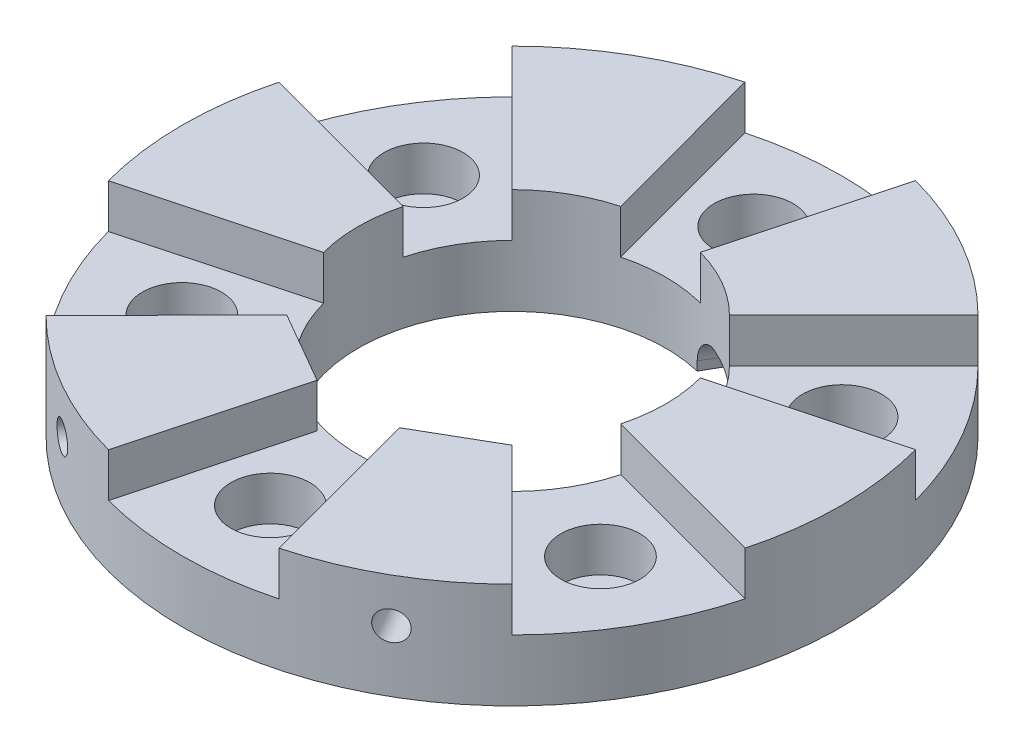
from build123d import *
from build123d.topology import SkipClean

# Parameters (mm, degrees)
SKETCH1_R               = 37.5
SKETCH1_R_2             = 2.3
BOSS_EXTRUDE1_DEPTH     = 2
SKETCH2_R               = 37.5
SKETCH2_R_2             = 4.5
BOSS_EXTRUDE2_DEPTH     = 5
BOSS_EXTRUDE3_DEPTH     = 5
CUT_EXTRUDE1_START      = -7
SKETCH4_R               = 17.5
CUT_EXTRUDE1_DEPTH      = 7
CUT_EXTRUDE2_DEPTH      = 7
CUT_EXTRUDE2_DEPTH_BACK = 2.5
CUT_EXTRUDE4_DEPTH      = 3
CUT_EXTRUDE4_DEPTH_BACK = 2.5
SKETCH10_R              = 1.65
CUT_EXTRUDE7_DEPTH      = 20
SKETCH9_R               = 1.65
CUT_EXTRUDE6_DEPTH      = 20
CUT_EXTRUDE8_DEPTH      = 4
FILLET1_R               = 3


with BuildPart() as part:
    # Sketch1 → Boss-Extrude1 (new body)
    with BuildSketch(Plane(origin=(0, 0, 0), x_dir=(1, 0, 0), z_dir=(0, 1, 0))):
        Circle(SKETCH1_R)
        with Locations((0, 27.5)):
            Circle(SKETCH1_R_2, mode=Mode.SUBTRACT)
        with Locations((23.815698604, 13.75)):
            Circle(SKETCH1_R_2, mode=Mode.SUBTRACT)
        with Locations((23.815698604, -13.75)):
            Circle(SKETCH1_R_2, mode=Mode.SUBTRACT)
        with Locations((0, -27.5)):
            Circle(SKETCH1_R_2, mode=Mode.SUBTRACT)
        with Locations((-23.815698604, -13.75)):
            Circle(SKETCH1_R_2, mode=Mode.SUBTRACT)
        with Locations((-23.815698604, 13.75)):
            Circle(SKETCH1_R_2, mode=Mode.SUBTRACT)
    extrude(amount=BOSS_EXTRUDE1_DEPTH)

    # Sketch2 → Boss-Extrude2 (add)
    with BuildSketch(Plane(origin=(0, 2, 0), x_dir=(1, 0, 0), z_dir=(0, 1, 0))):
        Circle(SKETCH2_R)
        with Locations((-23.815698604, -13.75)):
            Circle(SKETCH2_R_2, mode=Mode.SUBTRACT)
        with Locations((0, -27.5)):
            Circle(SKETCH2_R_2, mode=Mode.SUBTRACT)
        with Locations((23.815698604, -13.75)):
            Circle(SKETCH2_R_2, mode=Mode.SUBTRACT)
        with Locations((-23.815698604, 13.75)):
            Circle(SKETCH2_R_2, mode=Mode.SUBTRACT)
        with Locations((23.815698604, 13.75)):
            Circle(SKETCH2_R_2, mode=Mode.SUBTRACT)
        with Locations((0, 27.5)):
            Circle(SKETCH2_R_2, mode=Mode.SUBTRACT)
    extrude(amount=BOSS_EXTRUDE2_DEPTH)

    # Sketch3 → Boss-Extrude3 (add)
    with BuildSketch(Plane(origin=(0, 7, 0), x_dir=(1, 0, 0), z_dir=(0, 1, 0))):
        with BuildLine():
            Line((-26.527052262, 26.50595213), (-12.379291055, 12.369444327))
            ThreePointArc((-12.379291055, 12.369444327), (-8.756029172, 15.151962023), (-4.536058371, 16.901898546))
            Line((-4.536058371, 16.901898546), (-9.720125081, 36.218354027))
            ThreePointArc((-9.720125081, 36.218354027), (-18.762919655, 32.468490048), (-26.527052262, 26.50595213))
        make_face()
        with BuildLine():
            ThreePointArc((-16.901898546, -4.536058371), (-17.499998615, -0.006962688), (-16.905502698, 4.52260749))
            Line((-16.905502698, 4.52260749), (-36.226077211, 9.691301765))
            ThreePointArc((-36.226077211, 9.691301765), (-37.499997032, -0.014920046), (-36.218354027, -9.720125081))
            Line((-36.218354027, -9.720125081), (-16.901898546, -4.536058371))
        make_face()
        with BuildLine():
            ThreePointArc((4.52260749, 16.905502698), (8.743969443, 15.158924711), (12.369444327, 12.379291055))
            Line((12.369444327, 12.379291055), (26.50595213, 26.527052262))
            ThreePointArc((26.50595213, 26.527052262), (18.737077377, 32.483410095), (9.691301765, 36.226077211))
            Line((9.691301765, 36.226077211), (4.52260749, 16.905502698))
        make_face()
        with BuildLine():
            ThreePointArc((16.901898546, 4.536058371), (17.499998615, 0.006962688), (16.905502698, -4.52260749))
            Line((16.905502698, -4.52260749), (36.226077211, -9.691301765))
            ThreePointArc((36.226077211, -9.691301765), (37.499997032, 0.014920046), (36.218354027, 9.720125081))
            Line((36.218354027, 9.720125081), (16.901898546, 4.536058371))
        make_face()
        with BuildLine():
            Line((-12.805791077, -12.81598516), (-26.50595213, -26.527052262))
            ThreePointArc((-26.50595213, -26.527052262), (-18.737077377, -32.483410095), (-9.691301765, -36.226077211))
            Line((-9.691301765, -36.226077211), (-4.682147808, -17.501864262))
            Line((-4.682147808, -17.501864262), (-12.805791077, -12.81598516))
        make_face()
        with BuildLine():
            Line((12.819708432, -12.809511387), (4.694715176, -17.493072864))
            Line((4.694715176, -17.493072864), (9.720125081, -36.218354027))
            ThreePointArc((9.720125081, -36.218354027), (18.762919655, -32.468490048), (26.527052262, -26.50595213))
            Line((26.527052262, -26.50595213), (12.819708432, -12.809511387))
        make_face()
    extrude(amount=BOSS_EXTRUDE3_DEPTH)

    # Sketch4 → Cut-Extrude1 (cut)
    with SkipClean():  # the faces are left unmerged after this step: merging them gives an invalid solid
        with BuildSketch(Plane(origin=(0, 7, 0), x_dir=(1, 0, 0), z_dir=(0, 1, 0)).offset(CUT_EXTRUDE1_START)):
            Circle(SKETCH4_R)
        extrude(amount=CUT_EXTRUDE1_DEPTH, mode=Mode.SUBTRACT)

    # Sketch5 → Cut-Extrude2 (cut, two sides: drawn at the far end of the back side and taken through both)
    with SkipClean():  # the faces are left unmerged after this step: merging them gives an invalid solid
        with BuildSketch(Plane(origin=(-8.743969443, 0, 15.158924711), x_dir=(-0.8662242691872709, 0, -0.49965539671955755), z_dir=(0.49965539671955755, 0, -0.8662242691872709)).offset(-CUT_EXTRUDE2_DEPTH_BACK)):
            Polygon((-1.645448267, 9.85), (-3.290896534, 7), (-1.645448267, 4.15), (1.645448267, 4.15), (3.290896534, 7), (1.645448267, 9.85), align=None)
        extrude(amount=CUT_EXTRUDE2_DEPTH + CUT_EXTRUDE2_DEPTH_BACK, mode=Mode.SUBTRACT)

    # Sketch7 → Cut-Extrude4 (cut, two sides: drawn at the far end of the back side and taken through both)
    with SkipClean():  # the faces are left unmerged after this step: merging them gives an invalid solid
        with BuildSketch(Plane(origin=(8.739633736, 0, 15.161424807), x_dir=(-0.8663671318105545, 0, 0.49940764203038923), z_dir=(-0.49940764203038923, 0, -0.8663671318105545)).offset(-CUT_EXTRUDE4_DEPTH_BACK)):
            Polygon((-1.665737666, 9.85), (-3.311185933, 7), (-1.665737666, 4.15), (1.625158868, 4.15), (3.270607135, 7), (1.625158868, 9.85), align=None)
        extrude(amount=CUT_EXTRUDE4_DEPTH + CUT_EXTRUDE4_DEPTH_BACK, mode=Mode.SUBTRACT)

    # Sketch10 → Cut-Extrude7 (cut)
    with SkipClean():  # the faces are left unmerged after this step: merging them gives an invalid solid
        with BuildSketch(Plane(origin=(8.739633736, 0, 15.161424807), x_dir=(-0.8663671318105323, 0, 0.49940764203042776), z_dir=(-0.4994076420304278, 0, -0.8663671318105324))):
            with Locations((-0.020289399, 7)):
                Circle(SKETCH10_R)
        extrude(amount=-CUT_EXTRUDE7_DEPTH, mode=Mode.SUBTRACT)

    # Sketch9 → Cut-Extrude6 (cut)
    with SkipClean():  # the faces are left unmerged after this step: merging them gives an invalid solid
        with BuildSketch(Plane(origin=(-9.993107934, 0, 17.324485384), x_dir=(-0.866224269187271, 0, -0.4996553967195575), z_dir=(0.49965539671955744, 0, -0.8662242691872709))):
            with Locations((0, 6.9)):
                Circle(SKETCH9_R)
        extrude(amount=-CUT_EXTRUDE6_DEPTH, mode=Mode.SUBTRACT)

    # Sketch14 → Cut-Extrude8 (cut)
    with SkipClean():  # the faces are left unmerged after this step: merging them gives an invalid solid
        with BuildSketch(Plane.XZ):
            with BuildLine():
                Line((4.055127897, -17.023687548), (14.252458915, -34.685982974))
                ThreePointArc((14.252458915, -34.685982974), (18.75, -32.475952642), (22.912712953, -29.685982974))
                Line((22.912712953, -29.685982974), (12.715381935, -12.023687548))
                ThreePointArc((12.715381935, -12.023687548), (8.75, -15.155444566), (4.055127897, -17.023687548))
            make_face()
        extrude(amount=-CUT_EXTRUDE8_DEPTH, mode=Mode.SUBTRACT)

    # Fillet1
    fillet1_edges = [part.edges().sort_by_distance(p)[0] for p in [
        (17.814047444, 4, -20.854835261),
        (9.153793406, 4, -25.854835261),
    ]]
    fillet(fillet1_edges, radius=FILLET1_R)


solid = part.part
